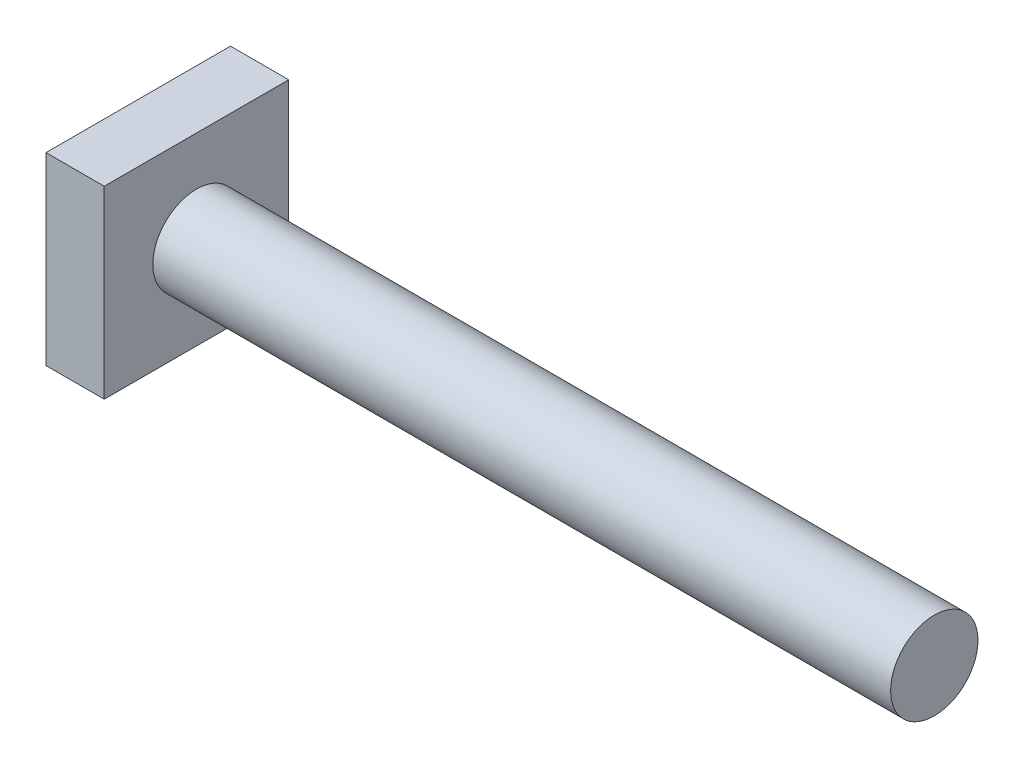
from build123d import *

# Parameters (mm, degrees)
SKETCH1_W           = 19
SKETCH1_H           = 19
BOSS_EXTRUDE1_DEPTH = 6
SKETCH2_R           = 4.5
BOSS_EXTRUDE2_DEPTH = 76


with BuildPart() as part:
    # Sketch1 → Boss-Extrude1 (new body)
    with BuildSketch(Plane(origin=(0, 0, 0), x_dir=(0, 0, -1), z_dir=(1, 0, 0))):
        Rectangle(SKETCH1_W, SKETCH1_H)
    extrude(amount=BOSS_EXTRUDE1_DEPTH)

    # Sketch2 → Boss-Extrude2 (add)
    with BuildSketch(Plane(origin=(6, 0, 0), x_dir=(0, 0, -1), z_dir=(1, 0, 0))):
        with Locations(Location((0, 0, 0), (0, 0, 180))):  # turned: the seam where the file's is
            Circle(SKETCH2_R)
    extrude(amount=BOSS_EXTRUDE2_DEPTH)


solid = part.part
